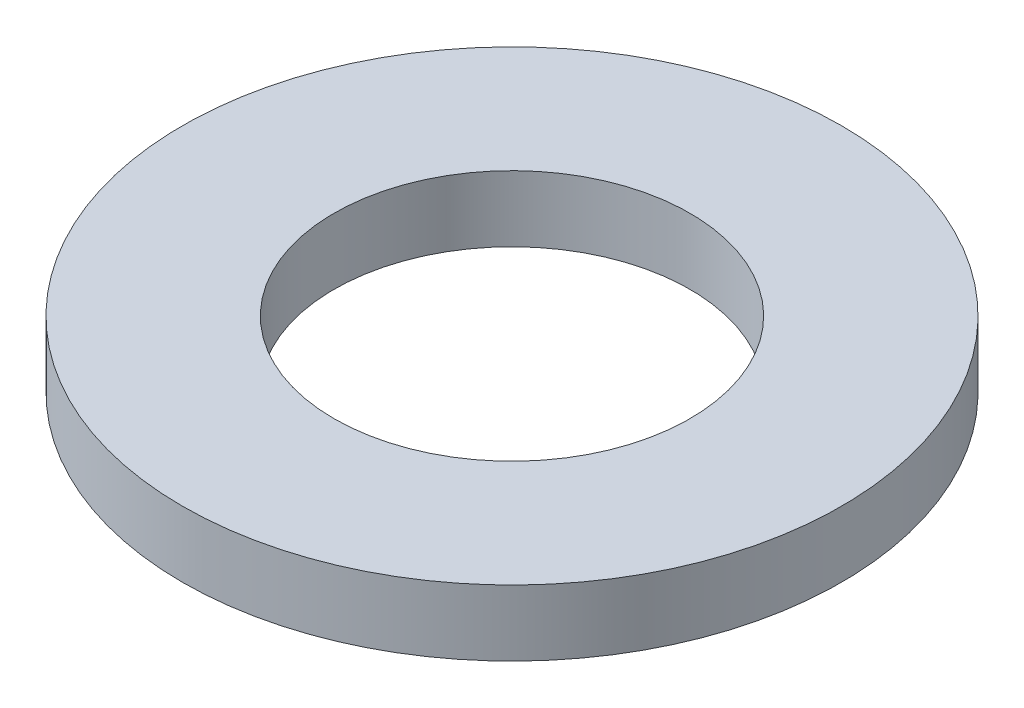
from build123d import *

# Parameters (mm, degrees)
ESBO_O1_R                = 5
ESBO_O1_R_2              = 2.7
RESSALTO_EXTRUS_O1_DEPTH = 1


with BuildPart() as part:
    # Esboço1 → Ressalto-extrusão1 (new body)
    with BuildSketch(Plane(origin=(0, 0, 0), x_dir=(1, 0, 0), z_dir=(0, 1, 0))):
        Circle(ESBO_O1_R)
        Circle(ESBO_O1_R_2, mode=Mode.SUBTRACT)
    extrude(amount=RESSALTO_EXTRUS_O1_DEPTH)


solid = part.part
